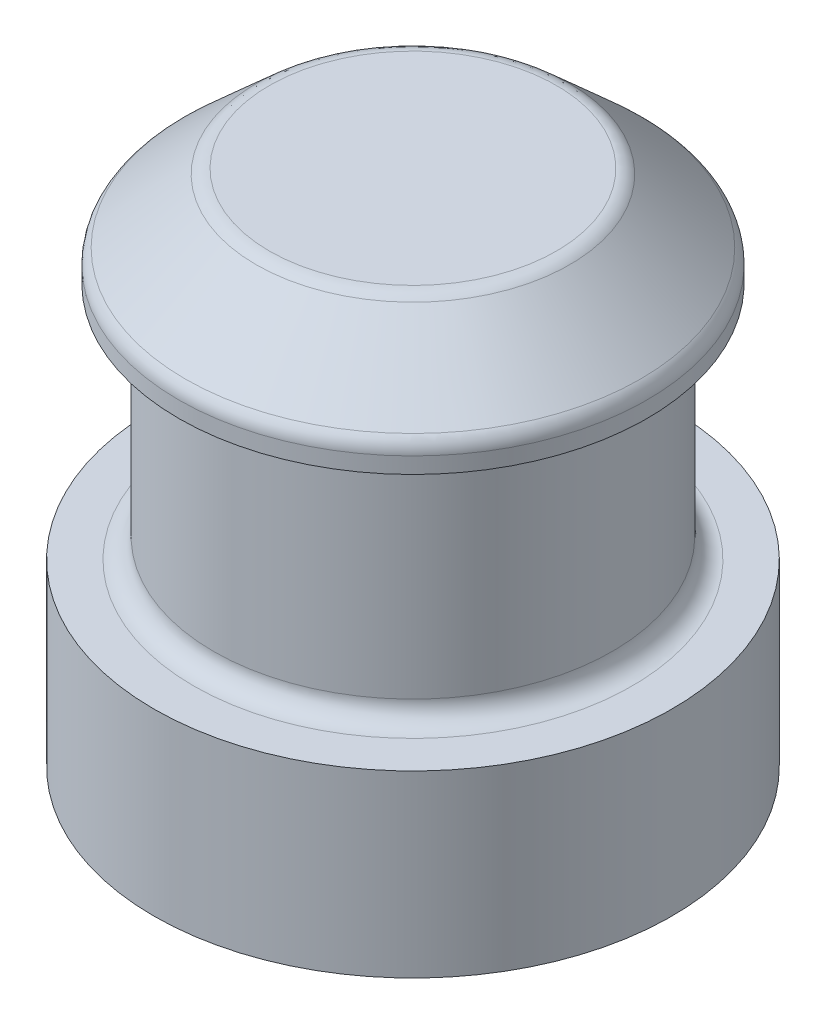
from build123d import *

# Parameters (mm, degrees)
SKETCH1_R           = 2.6
BOSS_EXTRUDE1_DEPTH = 1.8
SKETCH2_R           = 2
BOSS_EXTRUDE2_DEPTH = 2.4
SKETCH3_R           = 2.35
BOSS_EXTRUDE3_DEPTH = 1
CHAMFER1_SIZE       = 0.75
CHAMFER1_SIZE2      = 0.832959386
FILLET1_R           = 0.2
SCALE1_SCALE        = 1.15


with BuildPart() as part:
    # Sketch1 → Boss-Extrude1 (new body)
    with BuildSketch(Plane(origin=(0, 0, 0), x_dir=(1, 0, 0), z_dir=(0, 1, 0))):
        Circle(SKETCH1_R)
    extrude(amount=BOSS_EXTRUDE1_DEPTH)

    # Sketch2 → Boss-Extrude2 (add)
    with BuildSketch(Plane(origin=(0, 1.8, 0), x_dir=(1, 0, 0), z_dir=(0, 1, 0))):
        Circle(SKETCH2_R)
    extrude(amount=BOSS_EXTRUDE2_DEPTH)

    # Sketch3 → Boss-Extrude3 (add)
    with BuildSketch(Plane(origin=(0, 4.2, 0), x_dir=(1, 0, 0), z_dir=(0, 1, 0))):
        Circle(SKETCH3_R)
    extrude(amount=BOSS_EXTRUDE3_DEPTH)

    # Chamfer1
    chamfer1_edges = [part.edges().sort_by_distance(p)[0] for p in [
        (-2.35, 5.2, 0),
    ]]
    chamfer1_side = [part.faces().sort_by_distance(p)[0] for p in [
        (-2.35, 4.7, 0),
    ]]
    chamfer(chamfer1_edges, length=CHAMFER1_SIZE, length2=CHAMFER1_SIZE2, reference=chamfer1_side[0])

    # Fillet1
    fillet1_edges = [part.edges().sort_by_distance(p)[0] for p in [
        (-1.517040614, 5.2, 0),
        (-2.35, 4.45, 0),
        (-2, 1.8, 0),
    ]]
    fillet(fillet1_edges, radius=FILLET1_R)


with BuildPart() as part_1:
    # Scale1: scaled about (-4.2e-08, 2.280257944, 0)
    add(part.part.scale(SCALE1_SCALE).moved(Location((6e-09, -0.342038692, 0))))


solid = part_1.part
